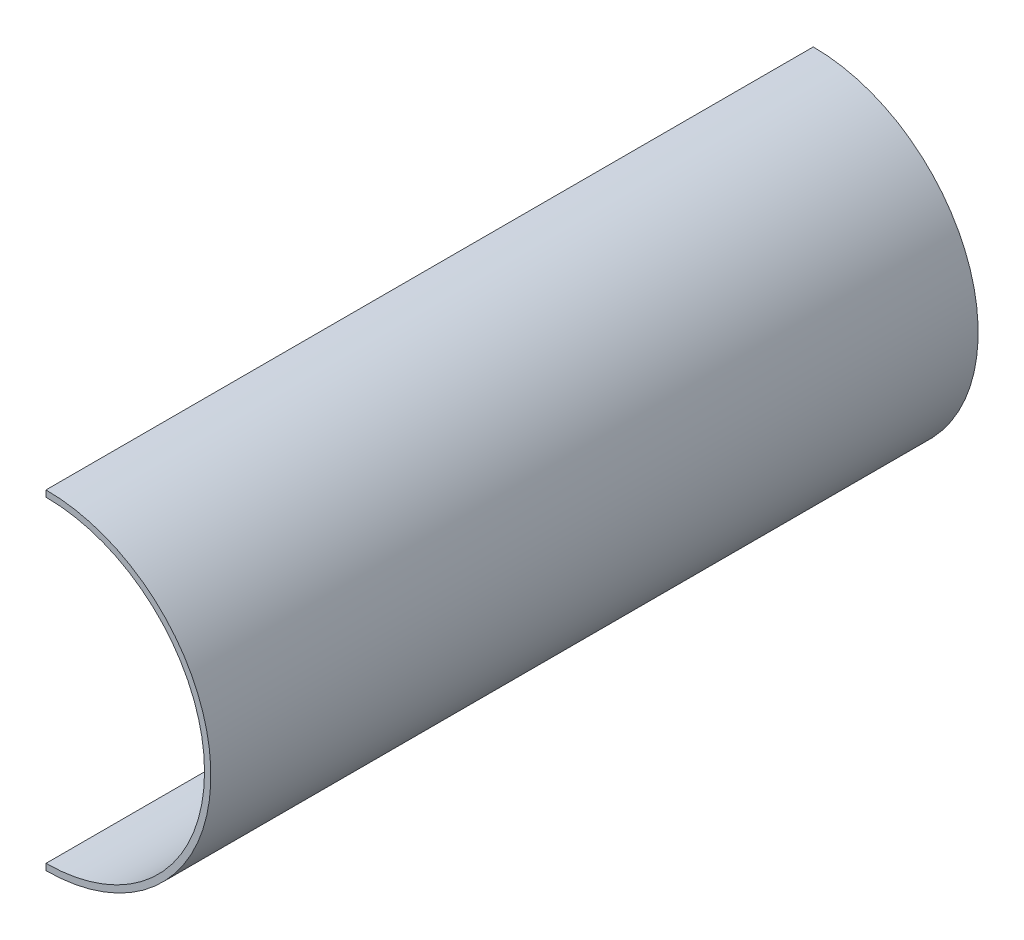
from build123d import *

# Parameters (mm, degrees)
EXTRUDE_1_DEPTH = 242
EXTRUDE_3_DEPTH = 1


with BuildPart() as part:
    # 草图1 → 凸台-拉伸1 (new body)
    with BuildSketch(Plane.XY):
        with BuildLine():
            Line((50, 52), (50, 50))
            ThreePointArc((50, 50), (62.940952255, 48.296291314), (75, 43.301270189))
            ThreePointArc((75, 43.301270189), (93.301270189, 25), (100, 0))
            ThreePointArc((100, 0), (93.301270189, -25), (75, -43.301270189))
            ThreePointArc((75, -43.301270189), (62.940952255, -48.296291314), (50, -50))
            Line((50, -50), (50, -52))
            ThreePointArc((50, -52), (63.458590345, -50.228142967), (76, -45.033320997))
            ThreePointArc((76, -45.033320997), (95.033320997, -26), (102, 0))
            ThreePointArc((102, 0), (95.033320997, 26), (76, 45.033320997))
            ThreePointArc((76, 45.033320997), (63.458590345, 50.228142967), (50, 52))
        make_face()
    extrude(amount=EXTRUDE_1_DEPTH)

    # 草图4 → 凸台-拉伸3 (add)
    with BuildSketch(Plane(origin=(0, 0, 2), x_dir=(-1, 0, 0), z_dir=(0, 0, -1))):
        with BuildLine():
            Line((-50, 50), (-50, 48))
            ThreePointArc((-50, 48), (-98, 0), (-50, -48))
            Line((-50, -48), (-50, -50))
            ThreePointArc((-50, -50), (-100, 0), (-50, 50))
        make_face()
    extrude(amount=-EXTRUDE_3_DEPTH)


solid = part.part
